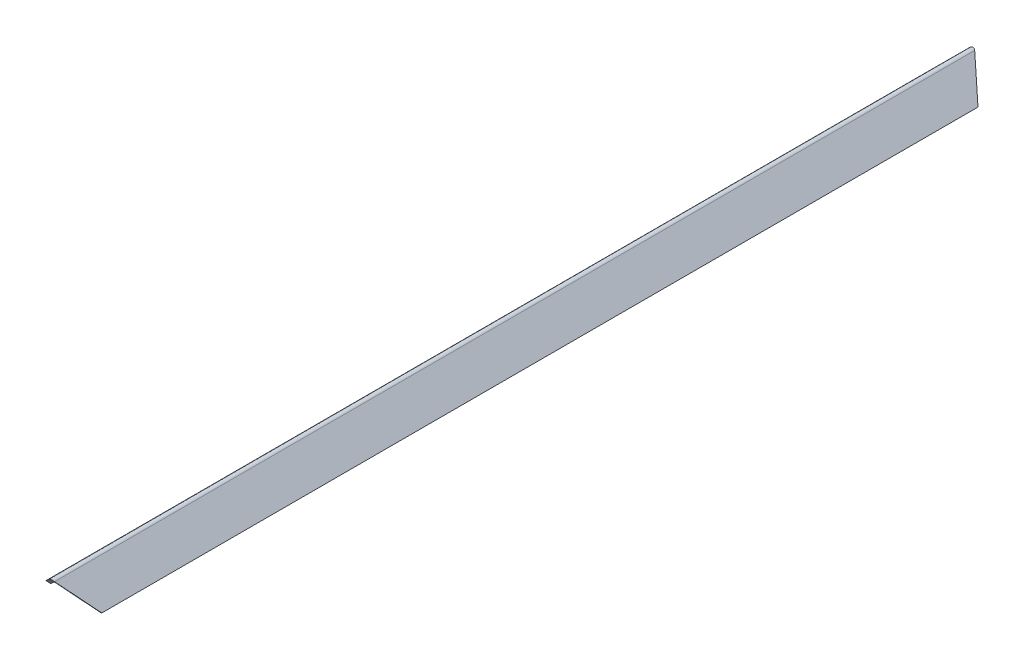
from build123d import *

# Parameters (mm, degrees)
BOSS_EXTRUDE1_DEPTH = 1631.95
CUT_EXTRUDE2_DEPTH  = 76.2
SKETCH11_W          = 116.748947554
SKETCH11_H          = 157.612376209
CUT_EXTRUDE3_DEPTH  = 76.2


with BuildPart() as part:
    # Sketch1 → Boss-Extrude1 (new body)
    with BuildSketch(Plane.XY):
        with BuildLine():
            Line((-43.879451284, -42.2312162), (-48.35985275, -37.73138257))
            Line((-48.35985275, -37.73138257), (-3.361516443, 7.07263209))
            ThreePointArc((-3.361516443, 7.07263209), (1.150121774, 8.929986414), (5.653679589, 7.053124274))
            Line((5.653679589, 7.053124274), (50.457694249, -37.945212032))
            Line((50.457694249, -37.945212032), (45.957860619, -42.425613498))
            Line((45.957860619, -42.425613498), (2.869929296, 0.849196564))
            ThreePointArc((2.869929296, 0.849196564), (1.073761457, 1.597033186), (-0.724615856, 0.854525573))
            Line((-0.724615856, 0.854525573), (-43.879451284, -42.2312162))
        make_face()
    extrude(amount=BOSS_EXTRUDE1_DEPTH)

    # Sketch10 → Cut-Extrude2 (cut)
    with BuildSketch(Plane(origin=(-1.739591993, -803.922021371, 927.063003524), x_dir=(0.999998995, -0.000928778, 0.001071044), z_dir=(-0.001417661, -0.655147382, 0.755499767))):
        Polygon((-72.388022704, 958.296853766), (-72.388022704, 1089.35007065), (76.019748324, 1091.938631218), (76.019748324, 958.296853766), align=None)
    extrude(amount=CUT_EXTRUDE2_DEPTH, mode=Mode.SUBTRACT)

    # Sketch11 → Cut-Extrude3 (cut)
    with BuildSketch(Plane(origin=(0.008296278, 3.83397994, 4.421250898), x_dir=(0.999998995, -0.000928778, -0.001071044), z_dir=(0.001417661, 0.655147382, 0.755499767))):
        with Locations((-6.183779703, -23.975283789)):
            Rectangle(SKETCH11_W, SKETCH11_H)
    extrude(amount=-CUT_EXTRUDE3_DEPTH, mode=Mode.SUBTRACT)


solid = part.part
